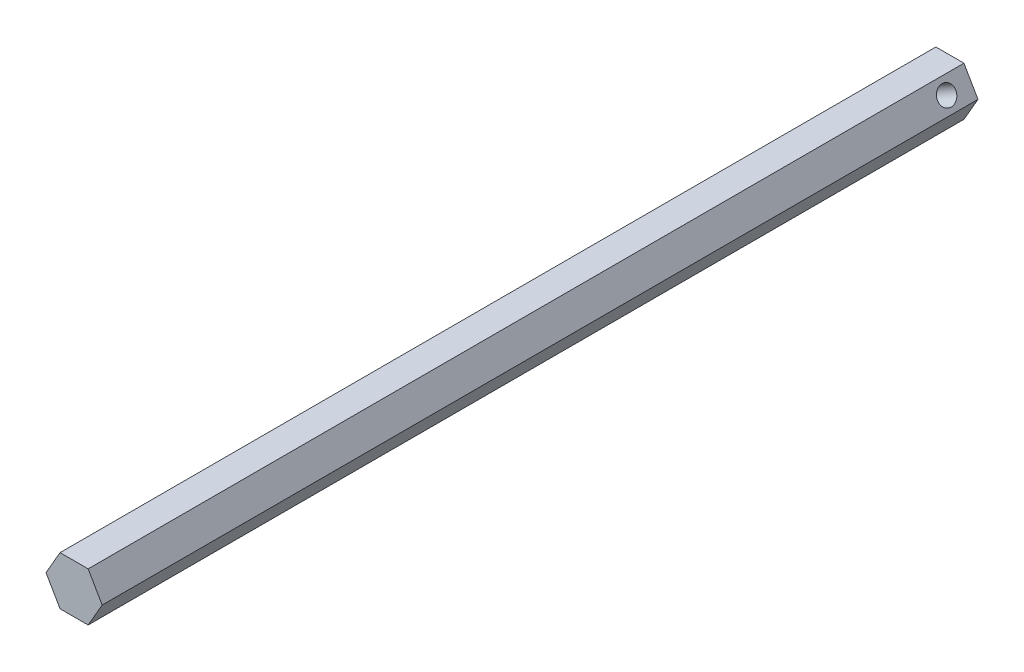
from build123d import *

# Parameters (mm, degrees)
BOSS_EXTRUDE1_DEPTH = 228.6
SKETCH2_R           = 2.38125
CUT_EXTRUDE1_DEPTH  = 16.875


with BuildPart() as part:
    # Sketch1 → Boss-Extrude1 (new body)
    with BuildSketch(Plane.XY):
        Polygon((-3.666174209, -6.35), (3.666174209, -6.35), (7.332348419, 0), (3.666174209, 6.35), (-3.666174209, 6.35), (-7.332348419, 0), align=None)
    extrude(amount=BOSS_EXTRUDE1_DEPTH)

    # Sketch2 → Cut-Extrude1 (cut, through all)
    with BuildSketch(Plane(origin=(5.499261314, 3.175, 0), x_dir=(0, 0, -1), z_dir=(0.866025404, 0.5, 0))):
        with Locations((-6.35, 0)):
            Circle(SKETCH2_R)
    extrude(amount=-CUT_EXTRUDE1_DEPTH, mode=Mode.SUBTRACT)


solid = part.part
